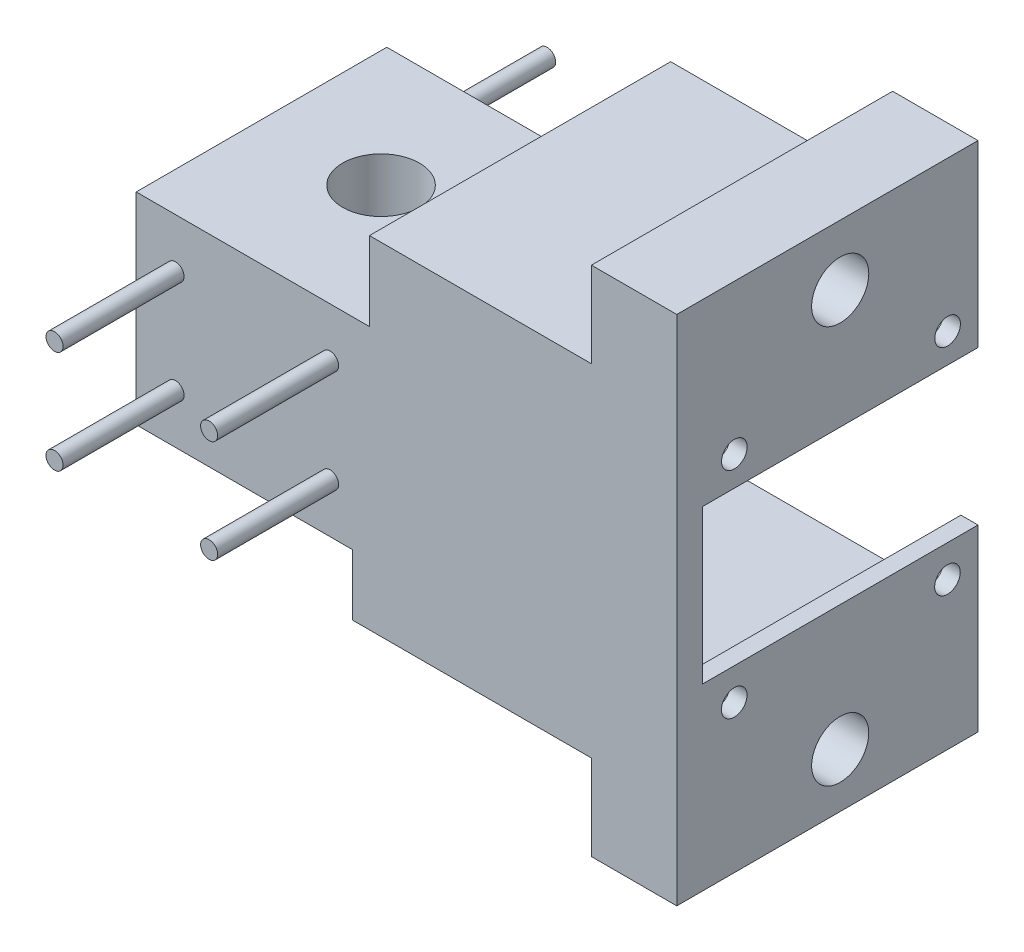
from build123d import *

# Parameters (mm, degrees)
SKETCH1_W            = 34.7
SKETCH1_H            = 30
BOSS_EXTRUDE1_DEPTH  = 37.282
SKETCH2_R            = 1.27
BOSS_EXTRUDE2_DEPTH  = 18
SKETCH4_R            = 5.715
CUT_EXTRUDE1_DEPTH   = 31
SKETCH5_R            = 1.625
BOSS_EXTRUDE4_DEPTH  = 5
SKETCH6_R            = 1.27
BOSS_EXTRUDE5_DEPTH  = 18
SKETCH8_W            = 3.81
SKETCH8_H            = 50.8
BOSS_EXTRUDE6_DEPTH  = 45.72
BOSS_EXTRUDE7_DEPTH  = 41.000001
CUT_EXTRUDE2_REACH   = 82.42
SKETCH10_R           = 1.905
SKETCH11_W           = 12.7
SKETCH11_H           = 44.810000611
BOSS_EXTRUDE8_DEPTH  = 12.7
SKETCH12_W           = 12.7
SKETCH12_H           = 44.810000611
BOSS_EXTRUDE9_DEPTH  = 12.7
SKETCH13_R           = 4.25
CUT_EXTRUDE3_DEPTH   = 6.35
SKETCH17_W           = 3.43592392
SKETCH17_H           = 45.72
BOSS_EXTRUDE12_DEPTH = 33.472
SKETCH16_W           = 2.5
SKETCH16_H           = 37.282
BOSS_EXTRUDE11_DEPTH = 9.076061


with BuildPart() as part:
    # Sketch1 → Boss-Extrude1 (new body)
    with BuildSketch(Plane(origin=(0, 0, -264.675), x_dir=(-1, 0, 0), z_dir=(0, 0, -1))):
        with Locations((-46.026450848, -396.896376681)):
            Rectangle(SKETCH1_W, SKETCH1_H)
    extrude(amount=BOSS_EXTRUDE1_DEPTH)

    # Sketch2 → Boss-Extrude2 (add)
    with BuildSketch(Plane.XY.offset(-264.675)):
        with Locations((34.526450848, -389.246376681)):
            Circle(SKETCH2_R)
        with Locations((57.526450848, -389.246376681)):
            Circle(SKETCH2_R)
        with Locations((57.526450848, -404.546376681)):
            Circle(SKETCH2_R)
        with Locations((34.526450848, -404.546376681)):
            Circle(SKETCH2_R)
    extrude(amount=BOSS_EXTRUDE2_DEPTH)

    # Sketch4 → Cut-Extrude1 (cut, through all)
    with BuildSketch(Plane(origin=(0, -381.896376681, 0), x_dir=(1, 0, 0), z_dir=(0, 1, 0))):
        with Locations((46.026450848, 283.749893694)):
            Circle(SKETCH4_R)
    extrude(amount=-CUT_EXTRUDE1_DEPTH, mode=Mode.SUBTRACT)

    # Sketch5 → Boss-Extrude4 (add)
    with BuildSketch(Plane.XZ.offset(411.896376681)):
        with Locations((46.453266338, -275.535975412)):
            Circle(SKETCH5_R)
        with Locations((54.24036913, -284.176709184)):
            Circle(SKETCH5_R)
        with Locations((45.599635358, -291.963811975)):
            Circle(SKETCH5_R)
        with Locations((37.812532567, -283.323078204)):
            Circle(SKETCH5_R)
    extrude(amount=BOSS_EXTRUDE4_DEPTH)

    # Sketch6 → Boss-Extrude5 (add)
    with BuildSketch(Plane(origin=(0, 0, -301.957), x_dir=(-1, 0, 0), z_dir=(0, 0, -1))):
        with Locations((-57.526450848, -389.246376681)):
            Circle(SKETCH6_R)
        with Locations((-34.526450848, -389.246376681)):
            Circle(SKETCH6_R)
        with Locations((-34.526450848, -404.546376681)):
            Circle(SKETCH6_R)
        with Locations((-57.526450848, -404.546376681)):
            Circle(SKETCH6_R)
    extrude(amount=BOSS_EXTRUDE5_DEPTH)

    # Sketch8 → Boss-Extrude6 (add)
    with BuildSketch(Plane(origin=(63.376450848, 0, 0), x_dir=(0, 0, -1), z_dir=(1, 0, 0))):
        with Locations((266.58, -395.572437442)):
            Rectangle(SKETCH8_W, SKETCH8_H)
    extrude(amount=BOSS_EXTRUDE6_DEPTH)

    # Sketch9 → Boss-Extrude7 (add)
    with BuildSketch(Plane(origin=(0, 0, -268.485), x_dir=(-1, 0, 0), z_dir=(0, 0, -1))):
        Polygon((-109.096450848, -370.172437442), (-63.376450848, -370.172437442), (-63.376450848, -372.712437442), (-106.556450848, -372.712437442), (-106.556450848, -384.142437442), (-109.096450848, -384.142437442), (-109.096450848, -372.712437442), align=None)
        Polygon((-109.096450848, -420.972437442), (-63.376450848, -420.972437442), (-63.376450848, -418.432437442), (-106.556450848, -418.432437442), (-106.556450848, -407.002437442), (-109.096450848, -407.002437442), (-109.096450848, -418.432437442), align=None)
    extrude(amount=BOSS_EXTRUDE7_DEPTH)

    # Sketch10 → Cut-Extrude2 (cut, up to next)
    with BuildSketch(Plane(origin=(109.096450848, 0, 0), x_dir=(0, 0, -1), z_dir=(1, 0, 0)), mode=Mode.PRIVATE) as cut_extrude2_sk1:
        with Locations((304.963451053, -379.773986799)):
            Circle(SKETCH10_R)
    cut_extrude2_tool1 = extrude(cut_extrude2_sk1.sketch, amount=-CUT_EXTRUDE2_REACH, mode=Mode.PRIVATE) & part.part
    add(cut_extrude2_tool1.solids().sort_by_distance((109.096451, -379.773987, -304.963451))[0], mode=Mode.SUBTRACT)
    # Sketch10 → Cut-Extrude2 (cut, up to next)
    with BuildSketch(Plane(origin=(109.096450848, 0, 0), x_dir=(0, 0, -1), z_dir=(1, 0, 0)), mode=Mode.PRIVATE) as cut_extrude2_sk2:
        with Locations((304.941901697, -411.752437852)):
            Circle(SKETCH10_R)
    cut_extrude2_tool2 = extrude(cut_extrude2_sk2.sketch, amount=-CUT_EXTRUDE2_REACH, mode=Mode.PRIVATE) & part.part
    add(cut_extrude2_tool2.solids().sort_by_distance((109.096451, -411.752438, -304.941902))[0], mode=Mode.SUBTRACT)
    # Sketch10 → Cut-Extrude2 (cut, up to next)
    with BuildSketch(Plane(origin=(109.096450848, 0, 0), x_dir=(0, 0, -1), z_dir=(1, 0, 0)), mode=Mode.PRIVATE) as cut_extrude2_sk3:
        with Locations((273.239000003, -379.752437442)):
            Circle(SKETCH10_R)
    cut_extrude2_tool3 = extrude(cut_extrude2_sk3.sketch, amount=-CUT_EXTRUDE2_REACH, mode=Mode.PRIVATE) & part.part
    add(cut_extrude2_tool3.solids().sort_by_distance((109.096451, -379.752437, -273.239))[0], mode=Mode.SUBTRACT)
    # Sketch10 → Cut-Extrude2 (cut, up to next)
    with BuildSketch(Plane(origin=(109.096450848, 0, 0), x_dir=(0, 0, -1), z_dir=(1, 0, 0)), mode=Mode.PRIVATE) as cut_extrude2_sk4:
        with Locations((273.221901697, -411.730888495)):
            Circle(SKETCH10_R)
    cut_extrude2_tool4 = extrude(cut_extrude2_sk4.sketch, amount=-CUT_EXTRUDE2_REACH, mode=Mode.PRIVATE) & part.part
    add(cut_extrude2_tool4.solids().sort_by_distance((109.096451, -411.730888, -273.221902))[0], mode=Mode.SUBTRACT)

    # Sketch11 → Boss-Extrude8 (add)
    with BuildSketch(Plane(origin=(0, -370.172437442, 0), x_dir=(1, 0, 0), z_dir=(0, 1, 0))):
        with Locations((102.746450848, 287.080000305)):
            Rectangle(SKETCH11_W, SKETCH11_H)
    extrude(amount=BOSS_EXTRUDE8_DEPTH)

    # Sketch12 → Boss-Extrude9 (add)
    with BuildSketch(Plane.XZ.offset(420.972437442)):
        with Locations((102.746450848, -287.080000305)):
            Rectangle(SKETCH12_W, SKETCH12_H)
    extrude(amount=BOSS_EXTRUDE9_DEPTH)

    # Sketch13 → Cut-Extrude3 (cut)
    with BuildSketch(Plane(origin=(109.096450848, 0, 0), x_dir=(0, 0, -1), z_dir=(1, 0, 0))):
        with Locations((288.985000522, -366.472437442)):
            Circle(SKETCH13_R)
        with Locations((288.985000522, -425.654437442)):
            Circle(SKETCH13_R)
    extrude(amount=-CUT_EXTRUDE3_DEPTH, mode=Mode.SUBTRACT)

    # Sketch17 → Boss-Extrude12 (add)
    with BuildSketch(Plane(origin=(0, 0, -268.485), x_dir=(-1, 0, 0), z_dir=(0, 0, -1))):
        with Locations((-65.094412808, -395.572437442)):
            Rectangle(SKETCH17_W, SKETCH17_H)
    extrude(amount=BOSS_EXTRUDE12_DEPTH)

    # Sketch16 → Boss-Extrude11 (add)
    with BuildSketch(Plane.XZ.offset(411.896376681)):
        with Locations((62.126450848, -283.316)):
            Rectangle(SKETCH16_W, SKETCH16_H)
    extrude(amount=BOSS_EXTRUDE11_DEPTH)


solid = part.part
